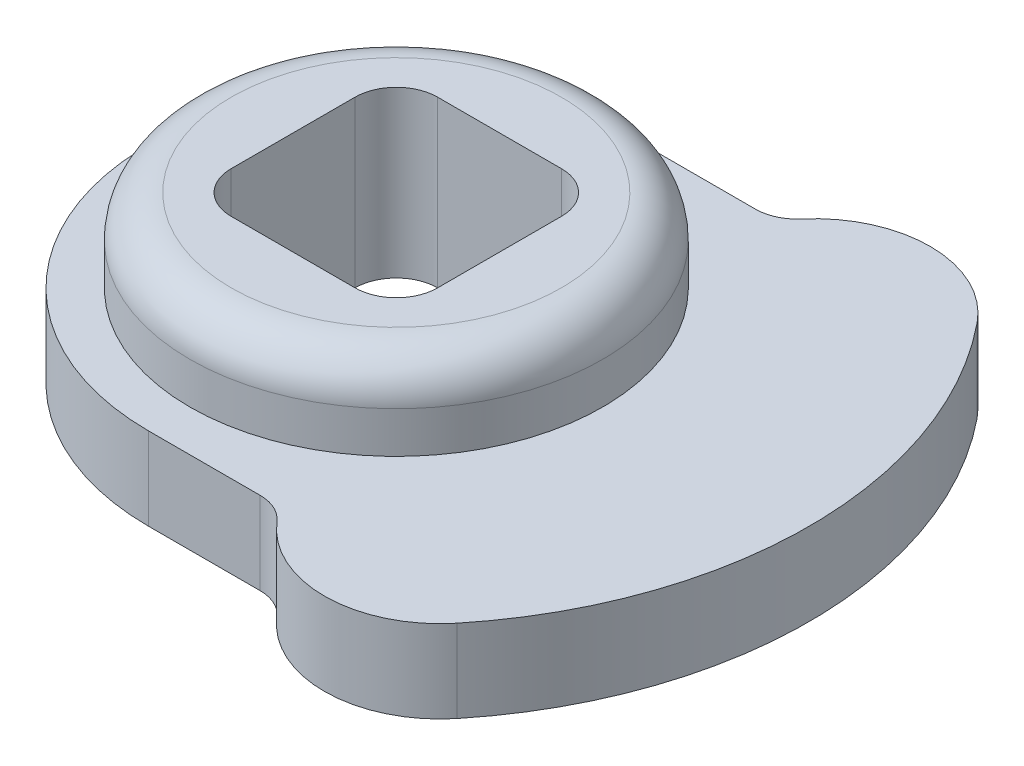
from build123d import *

# Parameters (mm, degrees)
SKETCH1_R           = 6.35
BOSS_EXTRUDE1_DEPTH = 5.08
BOSS_EXTRUDE2_DEPTH = 2.54
CUT_EXTRUDE1_DEPTH  = 6.08
FILLET1_R           = 1.27


with BuildPart() as part:
    # Sketch1 → Boss-Extrude1 (new body)
    with BuildSketch(Plane(origin=(0, 0, 0), x_dir=(1, 0, 0), z_dir=(0, 1, 0))):
        Circle(SKETCH1_R)
    extrude(amount=BOSS_EXTRUDE1_DEPTH)

    # Sketch3 → Boss-Extrude2 (add)
    with BuildSketch(Plane(origin=(0, 0, 0), x_dir=(1, 0, 0), z_dir=(0, 1, 0))):
        with BuildLine():
            Line((0, 7.62), (3.429, 7.62))
            ThreePointArc((3.429, 7.62), (3.961310007, 7.736940567), (4.395590669, 8.066226682))
            ThreePointArc((4.395590669, 8.066226682), (7.145413446, 9.315396919), (9.863950751, 7.99952971))
            ThreePointArc((9.863950751, 7.99952971), (12.7, 0), (9.863950751, -7.99952971))
            ThreePointArc((9.863950751, -7.99952971), (7.145413446, -9.315396919), (4.395590669, -8.066226682))
            ThreePointArc((4.395590669, -8.066226682), (3.961310007, -7.736940567), (3.429, -7.62))
            Line((3.429, -7.62), (0, -7.62))
            ThreePointArc((0, -7.62), (-7.62, 0), (0, 7.62))
        make_face()
    extrude(amount=BOSS_EXTRUDE2_DEPTH)

    # Sketch4 → Cut-Extrude1 (cut, through all)
    with BuildSketch(Plane(origin=(0, 5.08, 0), x_dir=(1, 0, 0), z_dir=(0, 1, 0))):
        with BuildLine():
            Line((-1.905, 3.175), (1.905, 3.175))
            ThreePointArc((1.905, 3.175), (2.803025612, 2.803025612), (3.175, 1.905))
            Line((3.175, 1.905), (3.175, -1.905))
            ThreePointArc((3.175, -1.905), (2.803025612, -2.803025612), (1.905, -3.175))
            Line((1.905, -3.175), (-1.905, -3.175))
            ThreePointArc((-1.905, -3.175), (-2.803025612, -2.803025612), (-3.175, -1.905))
            Line((-3.175, -1.905), (-3.175, 1.905))
            ThreePointArc((-3.175, 1.905), (-2.803025612, 2.803025612), (-1.905, 3.175))
        make_face()
    extrude(amount=-CUT_EXTRUDE1_DEPTH, mode=Mode.SUBTRACT)

    # Fillet1
    fillet1_edges = [part.edges().sort_by_distance(p)[0] for p in [
        (-6.35, 5.08, 0),
    ]]
    fillet(fillet1_edges, radius=FILLET1_R)


solid = part.part
